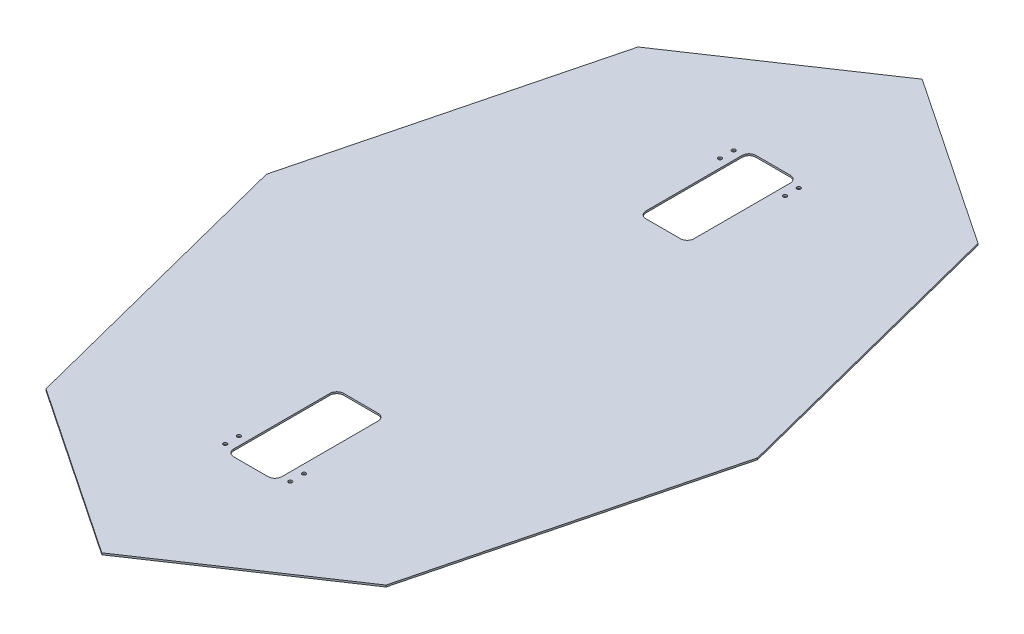
from build123d import *

# Parameters (mm, degrees)
BOSS_EXTRUDE1_DEPTH  = 1.5875
SKETCH2_W            = 88.9
SKETCH2_H            = 203.2
SKETCH2_R            = 3.429
CUT_EXTRUDE1_DEPTH   = 2.5875
FILLET1_R            = 12.7
FILLET1_OF_MIRROR1_R = 12.7


with BuildPart() as part:
    # Sketch1 → Boss-Extrude1 (new body, symmetric)
    with BuildSketch(Plane(origin=(0, 0, 0), x_dir=(1, 0, 0), z_dir=(0, 1, 0))):
        Polygon((-314.234696616, 547.119578242), (-453.923150307, 0), (-314.234696616, -547.119578242), (0, -758.175325655), (314.234696616, -547.119578242), (453.923150307, 0), (314.234696616, 547.119578242), (0, 758.175325655), align=None)
    extrude(amount=BOSS_EXTRUDE1_DEPTH, both=True)

    # Sketch2 → Cut-Extrude1 (cut, symmetric)
    with BuildSketch(Plane(origin=(0, 0, 0), x_dir=(1, 0, 0), z_dir=(0, 1, 0))):
        with Locations((0, 381)):
            Rectangle(SKETCH2_W, SKETCH2_H)
        with Locations((-60.198, 469.9)):
            Circle(SKETCH2_R)
        with Locations((-60.198, 444.5)):
            Circle(SKETCH2_R)
        with Locations((60.198, 444.5)):
            Circle(SKETCH2_R)
        with Locations((60.198, 469.9)):
            Circle(SKETCH2_R)
    cut_extrude1 = extrude(amount=CUT_EXTRUDE1_DEPTH, both=True, mode=Mode.SUBTRACT)

    # Fillet1
    fillet1_edges = [part.edges().sort_by_distance(p)[0] for p in [
        (44.45, 0, -279.4),
        (-44.45, 0, -279.4),
        (-44.45, 0, -482.6),
        (44.45, 0, -482.6),
    ]]
    fillet(fillet1_edges, radius=FILLET1_R)

    # Mirror1: Cut-Extrude1 across plane
    add(cut_extrude1.mirror(Plane.XY), mode=Mode.SUBTRACT)

    # Fillet1 of Mirror1
    fillet1_of_mirror1_edges = [part.edges().sort_by_distance(p)[0] for p in [
        (44.45, 0, 279.4),
        (-44.45, 0, 279.4),
        (-44.45, 0, 482.6),
        (44.45, 0, 482.6),
    ]]
    fillet(fillet1_of_mirror1_edges, radius=FILLET1_OF_MIRROR1_R)


solid = part.part
